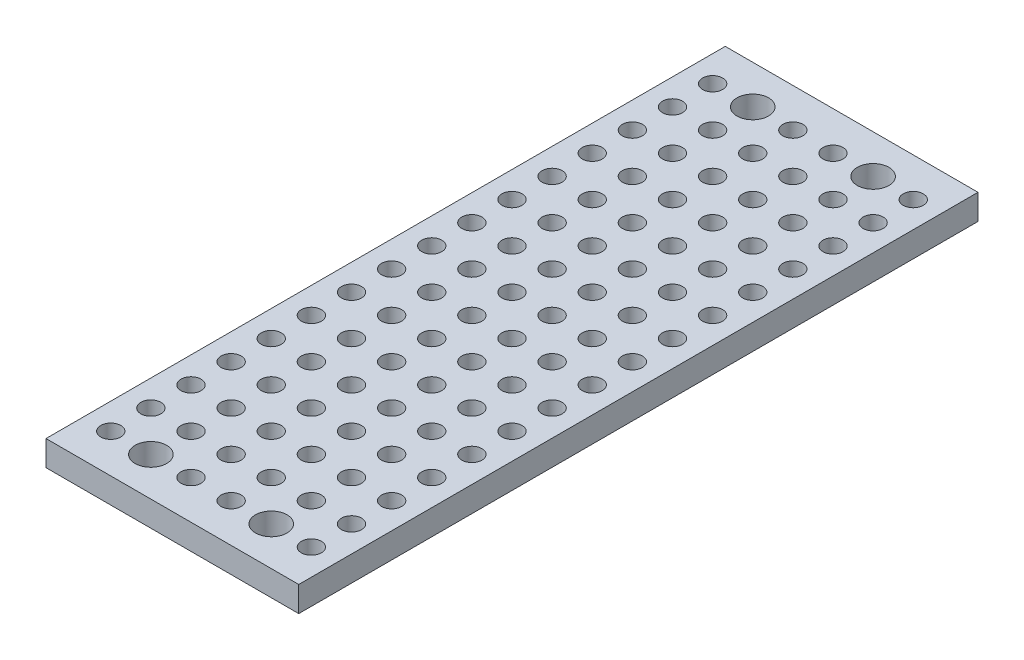
from build123d import *

# Parameters (mm, degrees)
SKETCH1_W                     = 16
SKETCH1_H                     = 43
BOSS_EXTRUDE1_DEPTH           = 1.6
F_6_0_05_DIAMETER_HOLE1_D     = 1.27
F_6_0_05_DIAMETER_HOLE1_DEPTH = 26.4
F_6_0_05_DIAMETER_HOLE1_TIP   = 0.381546493
SKETCH4_R                     = 1
CUT_EXTRUDE1_DEPTH            = 2.6


with BuildPart() as part:
    # Sketch1 → Boss-Extrude1 (new body)
    with BuildSketch(Plane(origin=(0, 0, 0), x_dir=(1, 0, 0), z_dir=(0, 1, 0))):
        Rectangle(SKETCH1_W, SKETCH1_H)
    extrude(amount=BOSS_EXTRUDE1_DEPTH)

    # #6 (0.05) Diameter Hole1
    with Locations(Plane(origin=(0, 1.6, 0), x_dir=(1, 0, 0), z_dir=(0, 1, 0))):
        with Locations((-6.35, 19.05), (-3.81, 19.05), (-1.27, 19.05), (1.27, 19.05), (3.81, 19.05), (6.35, 19.05), (-3.81, 16.51), (-1.27, 16.51), (1.27, 16.51), (3.81, 16.51), (6.35, 16.51), (-3.81, 13.97), (-1.27, 13.97), (1.27, 13.97), (3.81, 13.97), (6.35, 13.97), (-3.81, 11.43), (-1.27, 11.43), (1.27, 11.43), (3.81, 11.43), (6.35, 11.43), (-3.81, 8.89), (-1.27, 8.89), (1.27, 8.89), (3.81, 8.89), (6.35, 8.89), (-3.81, 6.35), (-1.27, 6.35), (1.27, 6.35), (3.81, 6.35), (6.35, 6.35), (-3.81, 3.81), (-1.27, 3.81), (1.27, 3.81), (3.81, 3.81), (6.35, 3.81), (-3.81, 1.27), (-1.27, 1.27), (1.27, 1.27), (3.81, 1.27), (6.35, 1.27), (-3.81, -1.27), (-1.27, -1.27), (1.27, -1.27), (3.81, -1.27), (6.35, -1.27), (-3.81, -3.81), (-1.27, -3.81), (1.27, -3.81), (3.81, -3.81), (6.35, -3.81), (-3.81, -6.35), (-1.27, -6.35), (1.27, -6.35), (3.81, -6.35), (6.35, -6.35), (-3.81, -8.89), (-1.27, -8.89), (1.27, -8.89), (3.81, -8.89), (6.35, -8.89), (-6.35, 16.51), (-6.35, 13.97), (-6.35, 11.43), (-6.35, 8.89), (-6.35, 6.35), (-6.35, 3.81), (-6.35, 1.27), (-6.35, -1.27), (-6.35, -3.81), (-6.35, -6.35), (-6.35, -8.89), (-6.35, -11.43), (-3.81, -11.43), (-1.27, -11.43), (1.27, -11.43), (3.81, -11.43), (6.35, -11.43), (-6.35, -13.97), (-3.81, -13.97), (-1.27, -13.97), (1.27, -13.97), (3.81, -13.97), (6.35, -13.97), (-6.35, -16.51), (-3.81, -16.51), (-1.27, -16.51), (1.27, -16.51), (3.81, -16.51), (6.35, -16.51), (-6.35, -19.05), (-3.81, -19.05), (-1.27, -19.05), (1.27, -19.05), (3.81, -19.05), (6.35, -19.05)):
            Hole(F_6_0_05_DIAMETER_HOLE1_D / 2, depth=F_6_0_05_DIAMETER_HOLE1_DEPTH)
            with Locations((0, 0, -(F_6_0_05_DIAMETER_HOLE1_DEPTH + F_6_0_05_DIAMETER_HOLE1_TIP / 2))):  # 118° drill point
                Cone(0, F_6_0_05_DIAMETER_HOLE1_D / 2, F_6_0_05_DIAMETER_HOLE1_TIP, mode=Mode.SUBTRACT)

    # Sketch4 → Cut-Extrude1 (cut, through all)
    with BuildSketch(Plane(origin=(0, 1.6, 0), x_dir=(1, 0, 0), z_dir=(0, 1, 0))):
        with Locations((-3.81, 19.05)):
            Circle(SKETCH4_R)
        with Locations((3.81, 19.05)):
            Circle(SKETCH4_R)
        with Locations((-3.81, -19.05)):
            Circle(SKETCH4_R)
        with Locations((3.81, -19.05)):
            Circle(SKETCH4_R)
    extrude(amount=-CUT_EXTRUDE1_DEPTH, mode=Mode.SUBTRACT)


solid = part.part
